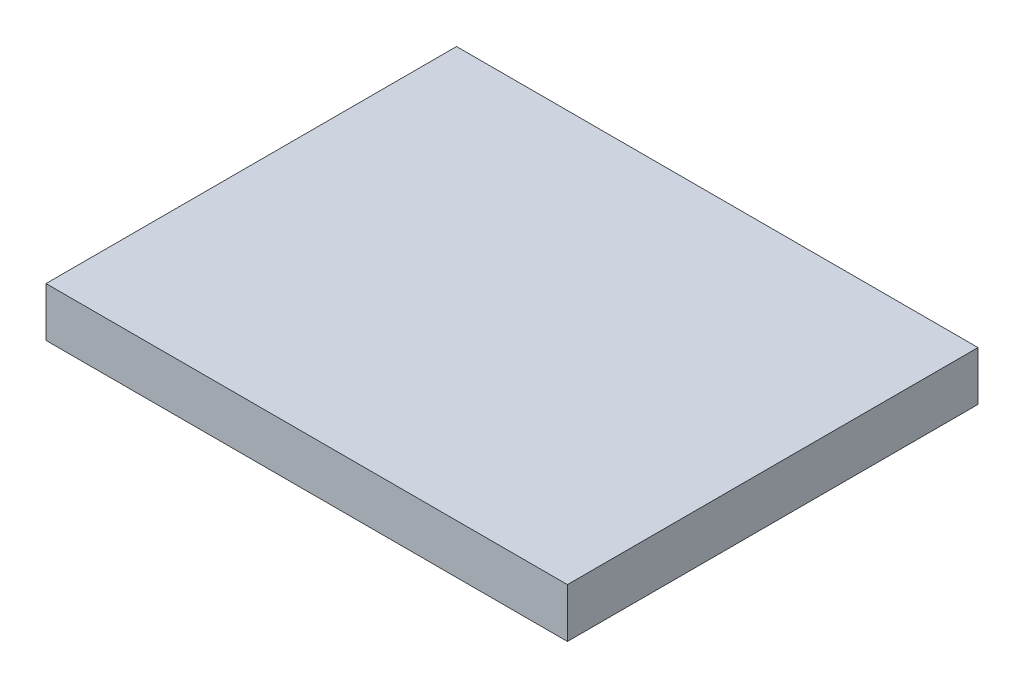
from build123d import *

# Parameters (mm, degrees)
SKETCH1_W           = 31.75
SKETCH1_H           = 25
BOSS_EXTRUDE1_DEPTH = 3


with BuildPart() as part:
    # Sketch1 → Boss-Extrude1 (new body)
    with BuildSketch(Plane(origin=(0, 0, 0), x_dir=(1, 0, 0), z_dir=(0, 1, 0))):
        Rectangle(SKETCH1_W, SKETCH1_H)
    extrude(amount=BOSS_EXTRUDE1_DEPTH)


solid = part.part
